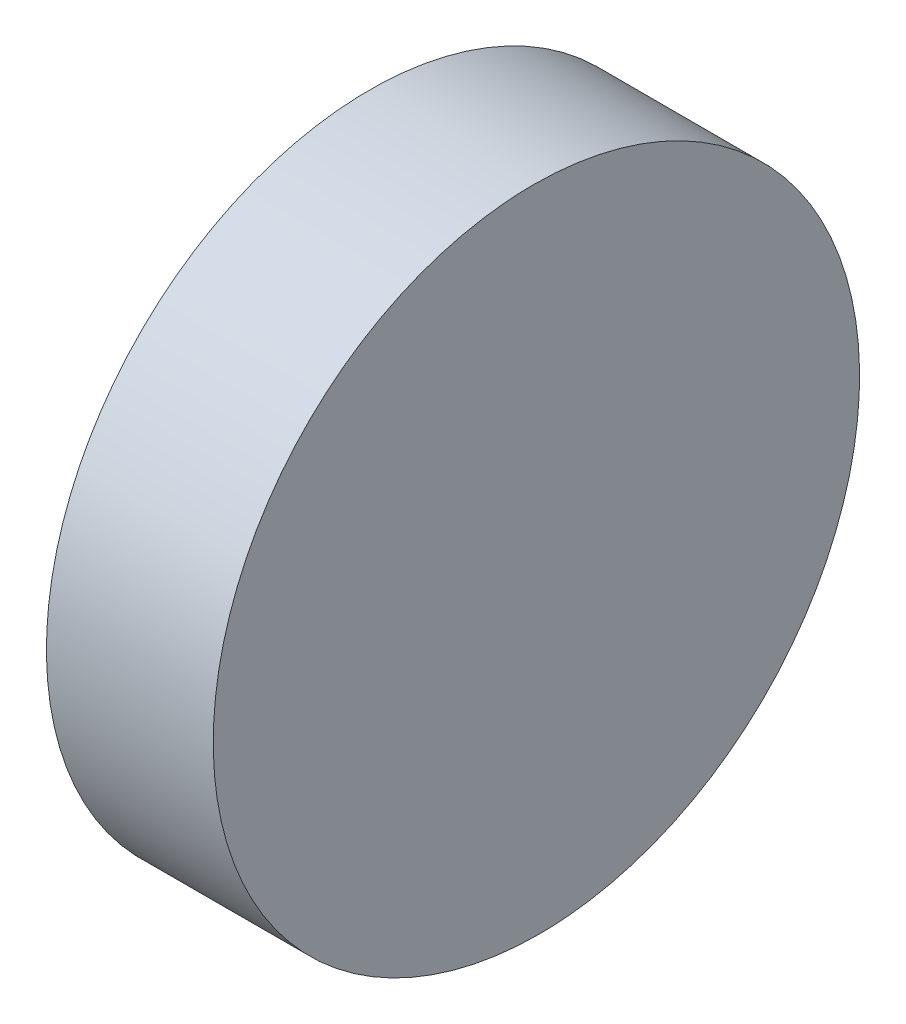
from build123d import *

# Parameters (mm, degrees)
EXTRUDE_1_DEPTH     = 38.1
CUT_EXTRUDE_1_DEPTH = 10


with BuildPart() as part:
    # 草图1 → 凸台-拉伸1 (new body)
    with BuildSketch(Plane.XY):
        Polygon((0, 19.05), (0, -19.05), (10, -19.05), (9.667506337, 19.05), align=None)
    extrude(amount=EXTRUDE_1_DEPTH)

    # 草图2 → 切除-拉伸1 (cut)
    with BuildSketch(Plane.ZY):
        with BuildLine():
            ThreePointArc((19.05, -19.05), (5.579615813, -13.470384177), (0, 1.4e-08))
            Line((0, 1.4e-08), (0, -19.05))
            Line((0, -19.05), (19.05, -19.05))
        make_face()
        with BuildLine():
            ThreePointArc((38.1, 0), (32.520384182, -13.470384182), (19.05, -19.05))
            Line((19.05, -19.05), (38.1, -19.05))
            Line((38.1, -19.05), (38.1, 0))
        make_face()
        with BuildLine():
            Line((38.1, 19.05), (19.05, 19.05))
            ThreePointArc((19.05, 19.05), (32.520384182, 13.470384182), (38.1, 0))
            Line((38.1, 0), (38.1, 19.05))
        make_face()
        with BuildLine():
            Line((19.05, 19.05), (0, 19.05))
            Line((0, 19.05), (0, 1.4e-08))
            ThreePointArc((0, 1.4e-08), (5.579615823, 13.470384187), (19.05, 19.05))
        make_face()
    extrude(amount=-CUT_EXTRUDE_1_DEPTH, mode=Mode.SUBTRACT)


solid = part.part
